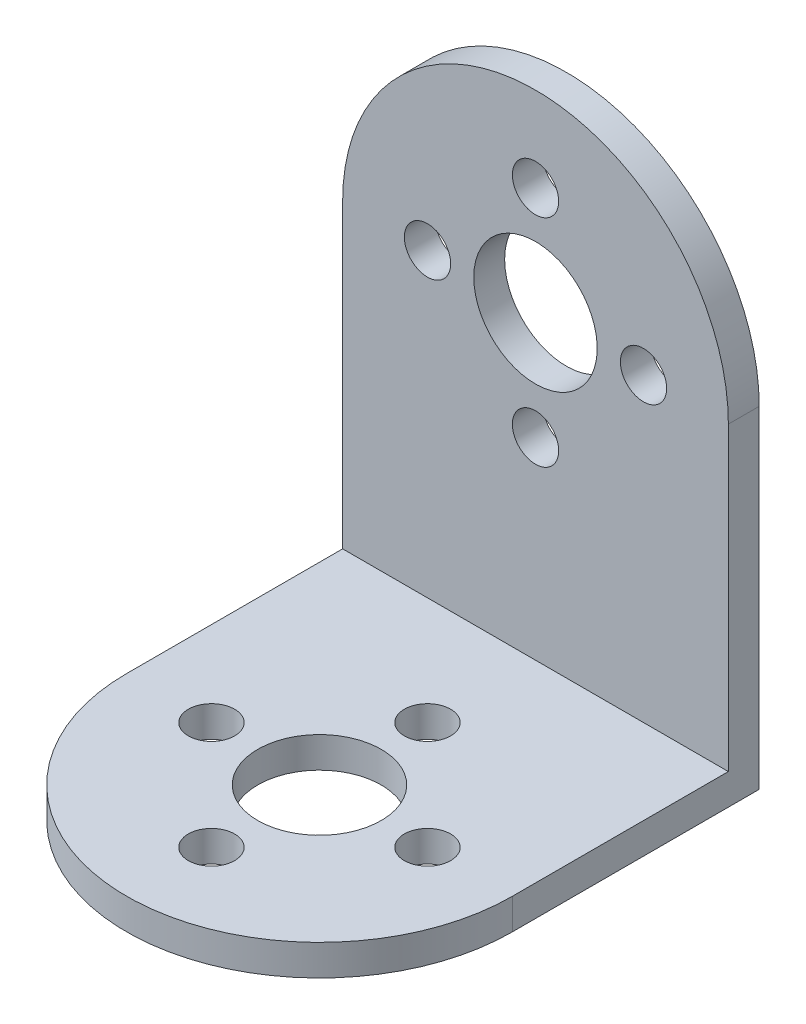
from build123d import *

# Parameters (mm, degrees)
SKETCH1_R           = 4
SKETCH1_R_2         = 1.5
BOSS_EXTRUDE1_DEPTH = 2
SKETCH2_R           = 4
SKETCH2_R_2         = 1.5
BOSS_EXTRUDE2_DEPTH = 2


with BuildPart() as part:
    # Sketch1 → Boss-Extrude1 (new body)
    with BuildSketch(Plane(origin=(0, 0, 0), x_dir=(1, 0, 0), z_dir=(0, 1, 0))):
        with BuildLine():
            Line((12.5, -7), (12.5, 7))
            Line((12.5, 7), (-12.5, 7))
            Line((-12.5, 7), (-12.5, -7))
            ThreePointArc((-12.5, -7), (0, -19.5), (12.5, -7))
        make_face()
        with Locations((0, -7)):
            Circle(SKETCH1_R, mode=Mode.SUBTRACT)
        Circle(SKETCH1_R_2, mode=Mode.SUBTRACT)
        with Locations((7, -7)):
            Circle(SKETCH1_R_2, mode=Mode.SUBTRACT)
        with Locations((-7, -7)):
            Circle(SKETCH1_R_2, mode=Mode.SUBTRACT)
        with Locations((0, -14)):
            Circle(SKETCH1_R_2, mode=Mode.SUBTRACT)
    extrude(amount=BOSS_EXTRUDE1_DEPTH)

    # Sketch2 → Boss-Extrude2 (add)
    with BuildSketch(Plane(origin=(0, 0, -7), x_dir=(-1, 0, 0), z_dir=(0, 0, -1))):
        with BuildLine():
            Line((-12.5, 0), (12.5, 0))
            Line((12.5, 0), (12.5, 21.5))
            ThreePointArc((12.5, 21.5), (0, 34), (-12.5, 21.5))
            Line((-12.5, 21.5), (-12.5, 0))
        make_face()
        with Locations((0, 21.5)):
            Circle(SKETCH2_R, mode=Mode.SUBTRACT)
        with Locations((0, 28.5)):
            Circle(SKETCH2_R_2, mode=Mode.SUBTRACT)
        with Locations((7, 21.5)):
            Circle(SKETCH2_R_2, mode=Mode.SUBTRACT)
        with Locations((0, 14.5)):
            Circle(SKETCH2_R_2, mode=Mode.SUBTRACT)
        with Locations((-7, 21.5)):
            Circle(SKETCH2_R_2, mode=Mode.SUBTRACT)
    extrude(amount=BOSS_EXTRUDE2_DEPTH)


solid = part.part
